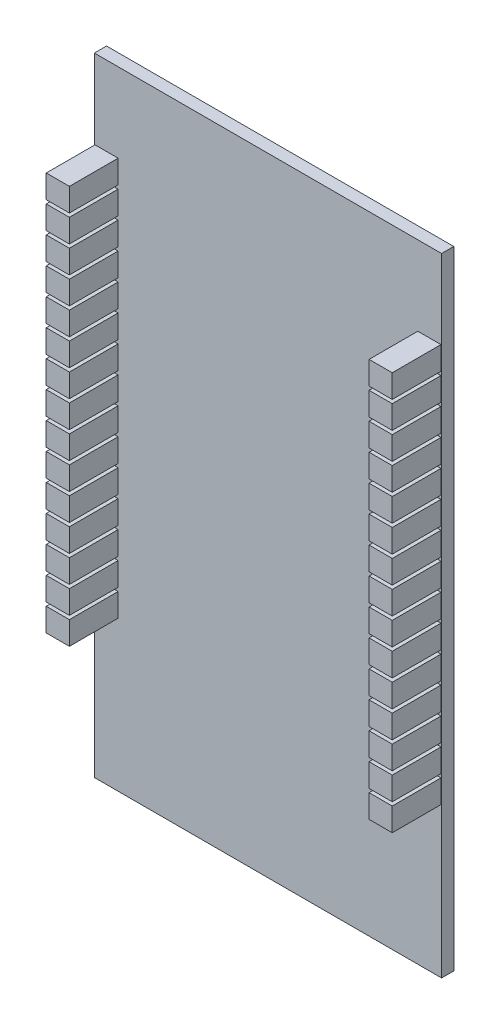
from build123d import *

# Parameters (mm, degrees)
SKETCH_1_W         = 28.5
SKETCH_1_H         = 51.5
EXTRUDE_1_DEPTH    = 1
SKETCH_2_W         = 1.9
SKETCH_2_H         = 1.9
EXTRUDE_2_DEPTH    = 4
EXTRUDE_2_2_DEPTH  = 4
EXTRUDE_2_3_DEPTH  = 4
EXTRUDE_2_4_DEPTH  = 4
EXTRUDE_2_5_DEPTH  = 4
EXTRUDE_2_6_DEPTH  = 4
EXTRUDE_2_7_DEPTH  = 4
EXTRUDE_2_8_DEPTH  = 4
EXTRUDE_2_9_DEPTH  = 4
EXTRUDE_2_10_DEPTH = 4
EXTRUDE_2_11_DEPTH = 4
EXTRUDE_2_12_DEPTH = 4
EXTRUDE_2_13_DEPTH = 4
EXTRUDE_2_14_DEPTH = 4
EXTRUDE_2_15_DEPTH = 4
EXTRUDE_2_16_DEPTH = 4
EXTRUDE_2_17_DEPTH = 4
EXTRUDE_2_18_DEPTH = 4
EXTRUDE_2_19_DEPTH = 4
EXTRUDE_2_20_DEPTH = 4
EXTRUDE_2_21_DEPTH = 4
EXTRUDE_2_22_DEPTH = 4
EXTRUDE_2_23_DEPTH = 4
EXTRUDE_2_24_DEPTH = 4
EXTRUDE_2_25_DEPTH = 4
EXTRUDE_2_26_DEPTH = 4
EXTRUDE_2_27_DEPTH = 4
EXTRUDE_2_28_DEPTH = 4
EXTRUDE_2_29_DEPTH = 4
EXTRUDE_2_30_DEPTH = 4
SKETCH_3_W         = 7.5
SKETCH_3_H         = 5
EXTRUDE_3_DEPTH    = 2.5


with BuildPart() as part:
    # ｽｹｯﾁ1 → ﾎﾞｽ - 押し出し1 (new body)
    with BuildSketch(Plane.XY):
        with Locations((14.25, 25.75)):
            Rectangle(SKETCH_1_W, SKETCH_1_H)
    extrude(amount=EXTRUDE_1_DEPTH)


with BuildPart() as body_2:
    # ｽｹｯﾁ2 → ﾎﾞｽ - 押し出し2 (new body)
    with BuildSketch(Plane.XY.offset(1)):
        with Locations((1, 44.05)):
            Rectangle(SKETCH_2_W, SKETCH_2_H)
    extrude(amount=EXTRUDE_2_DEPTH)


with BuildPart() as body_3:
    # ｽｹｯﾁ2 → Extrude 2 2 (new body)
    with BuildSketch(Plane.XY.offset(1)):
        with Locations((27.5, 44.05)):
            Rectangle(SKETCH_2_W, SKETCH_2_H)
    extrude(amount=EXTRUDE_2_2_DEPTH)


with BuildPart() as body_4:
    # ｽｹｯﾁ2 → Extrude 2 3 (new body)
    with BuildSketch(Plane.XY.offset(1)):
        with Locations((1, 41.85)):
            Rectangle(SKETCH_2_W, SKETCH_2_H)
    extrude(amount=EXTRUDE_2_3_DEPTH)


with BuildPart() as body_5:
    # ｽｹｯﾁ2 → Extrude 2 4 (new body)
    with BuildSketch(Plane.XY.offset(1)):
        with Locations((27.5, 41.85)):
            Rectangle(SKETCH_2_W, SKETCH_2_H)
    extrude(amount=EXTRUDE_2_4_DEPTH)


with BuildPart() as body_6:
    # ｽｹｯﾁ2 → Extrude 2 5 (new body)
    with BuildSketch(Plane.XY.offset(1)):
        with Locations((1, 39.65)):
            Rectangle(SKETCH_2_W, SKETCH_2_H)
    extrude(amount=EXTRUDE_2_5_DEPTH)


with BuildPart() as body_7:
    # ｽｹｯﾁ2 → Extrude 2 6 (new body)
    with BuildSketch(Plane.XY.offset(1)):
        with Locations((27.5, 39.65)):
            Rectangle(SKETCH_2_W, SKETCH_2_H)
    extrude(amount=EXTRUDE_2_6_DEPTH)


with BuildPart() as body_8:
    # ｽｹｯﾁ2 → Extrude 2 7 (new body)
    with BuildSketch(Plane.XY.offset(1)):
        with Locations((1, 37.45)):
            Rectangle(SKETCH_2_W, SKETCH_2_H)
    extrude(amount=EXTRUDE_2_7_DEPTH)


with BuildPart() as body_9:
    # ｽｹｯﾁ2 → Extrude 2 8 (new body)
    with BuildSketch(Plane.XY.offset(1)):
        with Locations((27.5, 37.45)):
            Rectangle(SKETCH_2_W, SKETCH_2_H)
    extrude(amount=EXTRUDE_2_8_DEPTH)


with BuildPart() as body_10:
    # ｽｹｯﾁ2 → Extrude 2 9 (new body)
    with BuildSketch(Plane.XY.offset(1)):
        with Locations((1, 35.25)):
            Rectangle(SKETCH_2_W, SKETCH_2_H)
    extrude(amount=EXTRUDE_2_9_DEPTH)


with BuildPart() as body_11:
    # ｽｹｯﾁ2 → Extrude 2 10 (new body)
    with BuildSketch(Plane.XY.offset(1)):
        with Locations((27.5, 35.25)):
            Rectangle(SKETCH_2_W, SKETCH_2_H)
    extrude(amount=EXTRUDE_2_10_DEPTH)


with BuildPart() as body_12:
    # ｽｹｯﾁ2 → Extrude 2 11 (new body)
    with BuildSketch(Plane.XY.offset(1)):
        with Locations((1, 33.05)):
            Rectangle(SKETCH_2_W, SKETCH_2_H)
    extrude(amount=EXTRUDE_2_11_DEPTH)


with BuildPart() as body_13:
    # ｽｹｯﾁ2 → Extrude 2 12 (new body)
    with BuildSketch(Plane.XY.offset(1)):
        with Locations((27.5, 33.05)):
            Rectangle(SKETCH_2_W, SKETCH_2_H)
    extrude(amount=EXTRUDE_2_12_DEPTH)


with BuildPart() as body_14:
    # ｽｹｯﾁ2 → Extrude 2 13 (new body)
    with BuildSketch(Plane.XY.offset(1)):
        with Locations((1, 30.85)):
            Rectangle(SKETCH_2_W, SKETCH_2_H)
    extrude(amount=EXTRUDE_2_13_DEPTH)


with BuildPart() as body_15:
    # ｽｹｯﾁ2 → Extrude 2 14 (new body)
    with BuildSketch(Plane.XY.offset(1)):
        with Locations((27.5, 30.85)):
            Rectangle(SKETCH_2_W, SKETCH_2_H)
    extrude(amount=EXTRUDE_2_14_DEPTH)


with BuildPart() as body_16:
    # ｽｹｯﾁ2 → Extrude 2 15 (new body)
    with BuildSketch(Plane.XY.offset(1)):
        with Locations((1, 28.65)):
            Rectangle(SKETCH_2_W, SKETCH_2_H)
    extrude(amount=EXTRUDE_2_15_DEPTH)


with BuildPart() as body_17:
    # ｽｹｯﾁ2 → Extrude 2 16 (new body)
    with BuildSketch(Plane.XY.offset(1)):
        with Locations((27.5, 28.65)):
            Rectangle(SKETCH_2_W, SKETCH_2_H)
    extrude(amount=EXTRUDE_2_16_DEPTH)


with BuildPart() as body_18:
    # ｽｹｯﾁ2 → Extrude 2 17 (new body)
    with BuildSketch(Plane.XY.offset(1)):
        with Locations((1, 26.45)):
            Rectangle(SKETCH_2_W, SKETCH_2_H)
    extrude(amount=EXTRUDE_2_17_DEPTH)


with BuildPart() as body_19:
    # ｽｹｯﾁ2 → Extrude 2 18 (new body)
    with BuildSketch(Plane.XY.offset(1)):
        with Locations((27.5, 26.45)):
            Rectangle(SKETCH_2_W, SKETCH_2_H)
    extrude(amount=EXTRUDE_2_18_DEPTH)


with BuildPart() as body_20:
    # ｽｹｯﾁ2 → Extrude 2 19 (new body)
    with BuildSketch(Plane.XY.offset(1)):
        with Locations((1, 24.25)):
            Rectangle(SKETCH_2_W, SKETCH_2_H)
    extrude(amount=EXTRUDE_2_19_DEPTH)


with BuildPart() as body_21:
    # ｽｹｯﾁ2 → Extrude 2 20 (new body)
    with BuildSketch(Plane.XY.offset(1)):
        with Locations((27.5, 24.25)):
            Rectangle(SKETCH_2_W, SKETCH_2_H)
    extrude(amount=EXTRUDE_2_20_DEPTH)


with BuildPart() as body_22:
    # ｽｹｯﾁ2 → Extrude 2 21 (new body)
    with BuildSketch(Plane.XY.offset(1)):
        with Locations((1, 22.05)):
            Rectangle(SKETCH_2_W, SKETCH_2_H)
    extrude(amount=EXTRUDE_2_21_DEPTH)


with BuildPart() as body_23:
    # ｽｹｯﾁ2 → Extrude 2 22 (new body)
    with BuildSketch(Plane.XY.offset(1)):
        with Locations((27.5, 22.05)):
            Rectangle(SKETCH_2_W, SKETCH_2_H)
    extrude(amount=EXTRUDE_2_22_DEPTH)


with BuildPart() as body_24:
    # ｽｹｯﾁ2 → Extrude 2 23 (new body)
    with BuildSketch(Plane.XY.offset(1)):
        with Locations((1, 19.85)):
            Rectangle(SKETCH_2_W, SKETCH_2_H)
    extrude(amount=EXTRUDE_2_23_DEPTH)


with BuildPart() as body_25:
    # ｽｹｯﾁ2 → Extrude 2 24 (new body)
    with BuildSketch(Plane.XY.offset(1)):
        with Locations((27.5, 19.85)):
            Rectangle(SKETCH_2_W, SKETCH_2_H)
    extrude(amount=EXTRUDE_2_24_DEPTH)


with BuildPart() as body_26:
    # ｽｹｯﾁ2 → Extrude 2 25 (new body)
    with BuildSketch(Plane.XY.offset(1)):
        with Locations((1, 17.65)):
            Rectangle(SKETCH_2_W, SKETCH_2_H)
    extrude(amount=EXTRUDE_2_25_DEPTH)


with BuildPart() as body_27:
    # ｽｹｯﾁ2 → Extrude 2 26 (new body)
    with BuildSketch(Plane.XY.offset(1)):
        with Locations((27.5, 17.65)):
            Rectangle(SKETCH_2_W, SKETCH_2_H)
    extrude(amount=EXTRUDE_2_26_DEPTH)


with BuildPart() as body_28:
    # ｽｹｯﾁ2 → Extrude 2 27 (new body)
    with BuildSketch(Plane.XY.offset(1)):
        with Locations((1, 15.45)):
            Rectangle(SKETCH_2_W, SKETCH_2_H)
    extrude(amount=EXTRUDE_2_27_DEPTH)


with BuildPart() as body_29:
    # ｽｹｯﾁ2 → Extrude 2 28 (new body)
    with BuildSketch(Plane.XY.offset(1)):
        with Locations((27.5, 15.45)):
            Rectangle(SKETCH_2_W, SKETCH_2_H)
    extrude(amount=EXTRUDE_2_28_DEPTH)


with BuildPart() as body_30:
    # ｽｹｯﾁ2 → Extrude 2 29 (new body)
    with BuildSketch(Plane.XY.offset(1)):
        with Locations((1, 13.25)):
            Rectangle(SKETCH_2_W, SKETCH_2_H)
    extrude(amount=EXTRUDE_2_29_DEPTH)


with BuildPart() as body_31:
    # ｽｹｯﾁ2 → Extrude 2 30 (new body)
    with BuildSketch(Plane.XY.offset(1)):
        with Locations((27.5, 13.25)):
            Rectangle(SKETCH_2_W, SKETCH_2_H)
    extrude(amount=EXTRUDE_2_30_DEPTH)


with BuildPart() as body_32:
    # ｽｹｯﾁ3 → ﾎﾞｽ - 押し出し3 (new body)
    with BuildSketch(Plane(origin=(0, 0, 0), x_dir=(-1, 0, 0), z_dir=(0, 0, -1))):
        with Locations((-14.25, 2.5)):
            Rectangle(SKETCH_3_W, SKETCH_3_H)
    extrude(amount=EXTRUDE_3_DEPTH)


solid = Compound([part.part, body_2.part, body_3.part, body_4.part, body_5.part, body_6.part, body_7.part, body_8.part, body_9.part, body_10.part, body_11.part, body_12.part, body_13.part, body_14.part, body_15.part, body_16.part, body_17.part, body_18.part, body_19.part, body_20.part, body_21.part, body_22.part, body_23.part, body_24.part, body_25.part, body_26.part, body_27.part, body_28.part, body_29.part, body_30.part, body_31.part, body_32.part])
